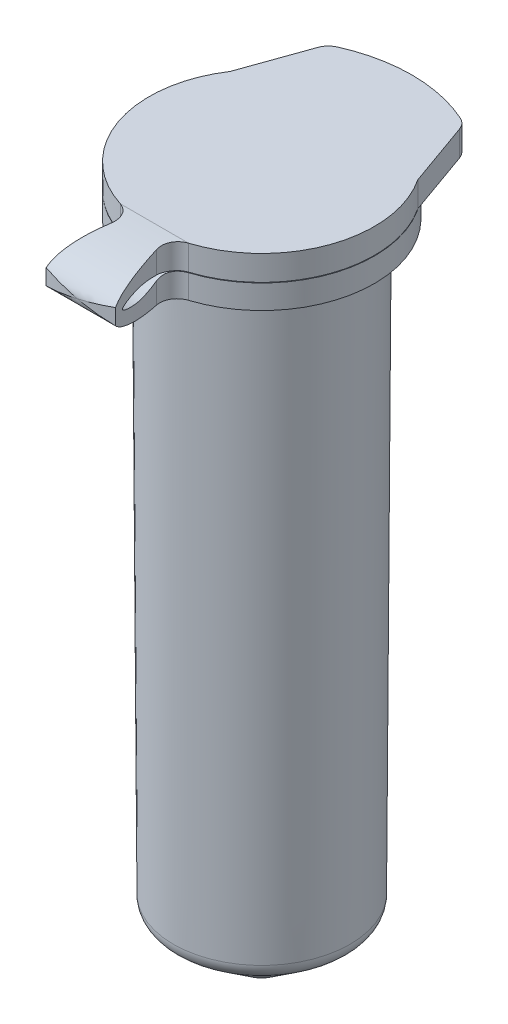
from build123d import *

# Parameters (mm, degrees)
BOSS_EXTRUDE1_DEPTH     = 1.47
BOSS_EXTRUDE2_REACH     = 44.45
CUT_EXTRUDE1_DEPTH      = 40.240986748
CUT_EXTRUDE1_DEPTH_BACK = 40.240986748


with BuildPart() as part:
    # Sketch1 → Revolve1 (revolve)
    with BuildSketch(Plane.XY, mode=Mode.PRIVATE) as revolve1_sk:
        with BuildLine():
            Line((1.192198173, -3.462113799), (4.773990196, -0.802910879))
            ThreePointArc((4.773990196, -0.802910879), (5.069930367, -0.451957922), (5.177874547, -0.005755483))
            Line((5.177874547, -0.005755483), (5.375, 34.243707959))
            Line((5.375, 34.243707959), (6.6, 34.243707959))
            Line((6.6, 34.243707959), (6.6, 35.643707959))
            Line((6.6, 35.643707959), (5.128724562, 35.643707959))
            Line((5.128724562, 35.643707959), (4.378724562, 34.893707959))
            Line((4.378724562, 34.893707959), (4.17789111, 0))
            Line((4.17789111, 0), (0.596099086, -2.65920292))
            ThreePointArc((0.596099086, -2.65920292), (0.31391808, -2.805742113), (0, -2.856292041))
            Line((0, -2.856292041), (0, -3.856292041))
            ThreePointArc((0, -3.856292041), (0.627836159, -3.755192185), (1.192198173, -3.462113799))
        make_face()
        Polygon((4.25, 32.893707959), (4.25, 36.393707959), (6, 36.393707959), (6, 35.673707959), (6.6, 35.673707959), (6.6, 36.140431751), (6.6, 37.143707959), (0, 37.143707959), (0, 36.393707959), (3.65, 36.393707959), (3.65, 32.893707959), align=None)
    revolve(revolve1_sk.sketch.rotate(Axis((0, 0, 0), (0, 1, 0)), 90), axis=Axis((0, 0, 0), (0, 1, 0)))

    # Sketch2 → Boss-Extrude1 (add)
    with BuildSketch(Plane(origin=(0, 37.143707959, 0), x_dir=(1, 0, 0), z_dir=(0, 1, 0))):
        with BuildLine():
            Line((-5.5, 3.648287269), (-4.147964107, 7.446102732))
            ThreePointArc((-4.147964107, 7.446102732), (-3.941225776, 7.788413444), (-3.616893324, 8.02234895))
            ThreePointArc((-3.616893324, 8.02234895), (0, 8.8), (3.616893324, 8.02234895))
            ThreePointArc((3.616893324, 8.02234895), (3.941225776, 7.788413444), (4.147964107, 7.446102732))
            Line((4.147964107, 7.446102732), (5.5, 3.648287269))
            ThreePointArc((5.5, 3.648287269), (0, 6.6), (-5.5, 3.648287269))
        make_face()
    extrude(amount=-BOSS_EXTRUDE1_DEPTH)

    # Boss-Extrude2: up to this face of the body (flat: up to its plane)
    boss_extrude2_end = Plane(part.part.faces().sort_by_distance((0, 34.243707959, 5.56167619))[0])
    # Sketch3 → Boss-Extrude2 (add, up to the picked face)
    with BuildSketch(Plane(origin=(0, 37.143707959, 0), x_dir=(1, 0, 0), z_dir=(0, 1, 0)), mode=Mode.PRIVATE) as boss_extrude2_sk1:
        with BuildLine():
            Line((0, -6.6), (0, -10.8))
            ThreePointArc((0, -10.8), (1.019553267, -10.751767814), (2.03, -10.607502062))
            ThreePointArc((2.03, -10.607502062), (1.706052324, -9.043133027), (1.335, -7.489262778))
            ThreePointArc((1.335, -7.489262778), (1.429653992, -6.757094078), (2.000871697, -6.289396828))
            ThreePointArc((2.000871697, -6.289396828), (1.01241813, -6.521886961), (0, -6.6))
        make_face()
    boss_extrude2_tool1 = split(extrude(boss_extrude2_sk1.sketch, amount=-BOSS_EXTRUDE2_REACH, mode=Mode.PRIVATE), bisect_by=boss_extrude2_end, keep=Keep.BOTH, mode=Mode.PRIVATE)
    # Sketch3 → Boss-Extrude2 (add, up to the picked face)
    with BuildSketch(Plane(origin=(0, 37.143707959, 0), x_dir=(1, 0, 0), z_dir=(0, 1, 0)), mode=Mode.PRIVATE) as boss_extrude2_sk2:
        with BuildLine():
            ThreePointArc((-2.03, -10.607502062), (-1.019553267, -10.751767814), (0, -10.8))
            Line((0, -10.8), (0, -6.6))
            ThreePointArc((0, -6.6), (-1.01241813, -6.521886961), (-2.000871697, -6.289396828))
            ThreePointArc((-2.000871697, -6.289396828), (-1.429653992, -6.757094078), (-1.335, -7.489262778))
            ThreePointArc((-1.335, -7.489262778), (-1.706052324, -9.043133027), (-2.03, -10.607502062))
        make_face()
    boss_extrude2_tool2 = split(extrude(boss_extrude2_sk2.sketch, amount=-BOSS_EXTRUDE2_REACH, mode=Mode.PRIVATE), bisect_by=boss_extrude2_end, keep=Keep.BOTH, mode=Mode.PRIVATE)
    add(boss_extrude2_tool1.solids().sort_by(Axis((0.832919, 37.143708, 8.79495), (0, -1, 0)))[0])
    add(boss_extrude2_tool2.solids().sort_by(Axis((-0.832919, 37.143708, 8.79495), (0, -1, 0)))[0])

    # Sketch5 → Cut-Extrude1 (cut, two sides)
    with BuildSketch(Plane(origin=(0, 0, 0), x_dir=(0, 0, -1), z_dir=(1, 0, 0))) as cut_extrude1_sk:
        with BuildLine():
            Line((-6.289396828, 35.643707959), (-6.6, 35.643707959))
            add(Edge.make_bspline(
                [(-6.6, 35.673707959), (-7.519037203, 35.673707959), (-8.421750075, 36.327077496), (-10.369945566, 35.658707959), (-8.421586809, 34.990338421), (-7.521291173, 35.643707959), (-6.6, 35.643707959)],
                knots=[0, 0, 0, 0, 0.417765924, 0.5, 0.582234076, 1, 1, 1, 1], degree=3))
            Line((-6.6, 35.673707959), (-6.289396828, 35.673707959))
            Line((-6.289396828, 35.673707959), (-6.289396828, 35.643707959))
        make_face()
        with BuildLine():
            Line((-6.289396828, 34.243707959), (-6.289396828, 33.533396672))
            Line((-6.289396828, 33.533396672), (-11.467394827, 33.825492735))
            Line((-11.467394827, 33.825492735), (-11.357937817, 38.544473635))
            Line((-11.357937817, 38.544473635), (-6.289396828, 38.035452095))
            Line((-6.289396828, 38.035452095), (-6.289396828, 37.143707959))
            add(Edge.make_bspline(
                [(-6.289396828, 37.143707959), (-9.431918588, 37.143707959), (-12.135369897, 35.479054802), (-9.496663947, 34.243707959), (-6.289396828, 34.243707959)],
                knots=[0, 0, 0, 0, 0.503821902, 1, 1, 1, 1], degree=3))
        make_face()
    extrude(amount=CUT_EXTRUDE1_DEPTH, mode=Mode.SUBTRACT)
    extrude(cut_extrude1_sk.sketch, amount=-CUT_EXTRUDE1_DEPTH_BACK, mode=Mode.SUBTRACT)


solid = part.part
